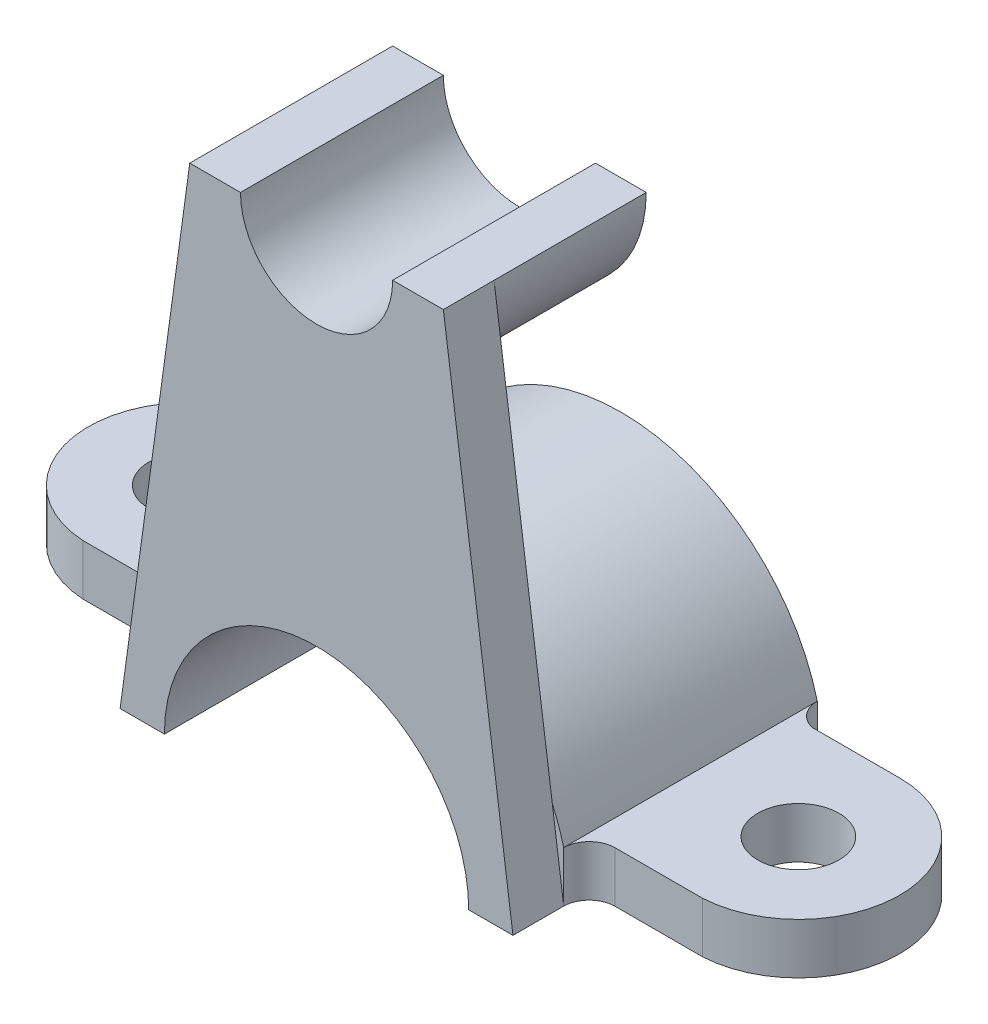
from build123d import *

# Parameters (mm, degrees)
BOSS_EXTRUDE1_DEPTH = 25
SKETCH2_R           = 8
CUT_EXTRUDE1_DEPTH  = 11
BOSS_EXTRUDE2_DEPTH = 10
CUT_EXTRUDE2_DEPTH  = 11
BOSS_EXTRUDE3_DEPTH = 30
CUT_EXTRUDE4_DEPTH  = 41


with BuildPart() as part:
    # Sketch1 → Boss-Extrude1 (new body, symmetric)
    with BuildSketch(Plane.XY):
        with BuildLine():
            Line((30, 0), (90, 0))
            Line((90, 0), (90, 10))
            Line((90, 10), (38.729833462, 10))
            ThreePointArc((38.729833462, 10), (0, 40), (-38.729833462, 10))
            Line((-38.729833462, 10), (-90, 10))
            Line((-90, 10), (-90, 0))
            Line((-90, 0), (-30, 0))
            ThreePointArc((-30, 0), (0, 30), (30, 0))
        make_face()
    extrude(amount=BOSS_EXTRUDE1_DEPTH, both=True)

    # Sketch2 → Cut-Extrude1 (cut, through all)
    with BuildSketch(Plane(origin=(0, 10, 0), x_dir=(1, 0, 0), z_dir=(0, 1, 0))):
        with Locations(Location((-60, 0, 0), (0, 0, 180))):  # turned: the seam where the file's is
            Circle(SKETCH2_R)
        with BuildLine():
            Line((-42.759901773, 20), (-60, 20))
            ThreePointArc((-60, 20), (-79.992623239, 0.543153766), (-61.08590686, -19.970498399))
            Line((-61.08590686, -19.970498399), (-43.845808633, -19.970498399))
            ThreePointArc((-43.845808633, -19.970498399), (-40.258710631, -21.438445011), (-38.729833462, -25))
            Line((-38.729833462, -25), (-90, -25))
            Line((-90, -25), (-90, 25))
            Line((-90, 25), (-38.729833462, 25))
            ThreePointArc((-38.729833462, 25), (-39.862779167, 21.789024658), (-42.759901773, 20))
        make_face()
    cut_extrude1 = extrude(amount=-CUT_EXTRUDE1_DEPTH, mode=Mode.SUBTRACT)

    # Mirror1: Cut-Extrude1 across plane
    add(cut_extrude1.mirror(Plane(origin=(0, 0, 0), x_dir=(0, 0, 1), z_dir=(1, 0, 0))), mode=Mode.SUBTRACT)

    # Sketch3 → Boss-Extrude2 (add)
    with BuildSketch(Plane.XY.offset(25)):
        Polygon((38.729833462, 0), (-38.729833462, 0), (-25, 100), (25, 100), align=None)
    extrude(amount=BOSS_EXTRUDE2_DEPTH)

    # Sketch5 → Cut-Extrude2 (cut, through all)
    with BuildSketch(Plane(origin=(0, 0, 25), x_dir=(-1, 0, 0), z_dir=(0, 0, -1))):
        with BuildLine():
            ThreePointArc((30, 0), (0, 30), (-30, 0))
            Line((-30, 0), (30, 0))
        make_face()
    extrude(amount=-CUT_EXTRUDE2_DEPTH, mode=Mode.SUBTRACT)

    # Sketch10 → Boss-Extrude3 (add)
    with BuildSketch(Plane(origin=(0, 0, 25), x_dir=(-1, 0, 0), z_dir=(0, 0, -1))):
        with BuildLine():
            Line((-25, 100), (25, 100))
            ThreePointArc((25, 100), (0, 75), (-25, 100))
        make_face()
    extrude(amount=BOSS_EXTRUDE3_DEPTH)

    # Sketch11 → Cut-Extrude4 (cut, through all)
    with BuildSketch(Plane(origin=(0, 0, -5), x_dir=(-1, 0, 0), z_dir=(0, 0, -1))):
        with BuildLine():
            Line((15, 100), (-15, 100))
            ThreePointArc((-15, 100), (0, 85), (15, 100))
        make_face()
    extrude(amount=-CUT_EXTRUDE4_DEPTH, mode=Mode.SUBTRACT)


solid = part.part
